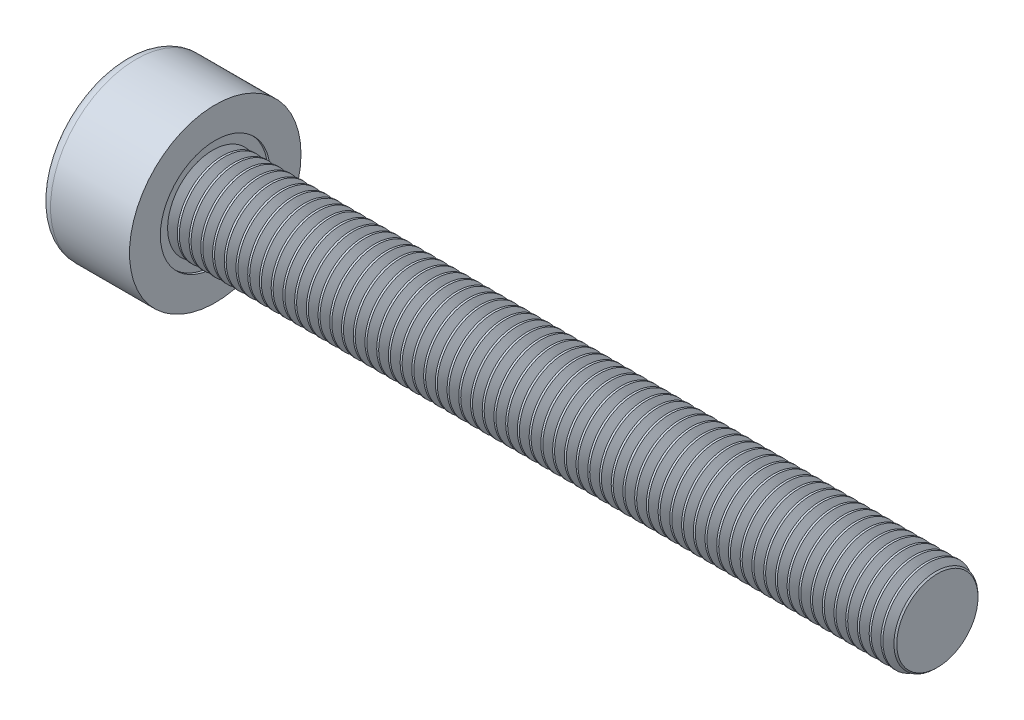
from build123d import *

# Parameters (mm, degrees)
SKETCH1_R           = 1.9
BASEHEAD_DEPTH      = 2
SKETCH2_R           = 1
BASEBODY_DEPTH      = 16
HEXAGONSOCKET_DEPTH = 1
TOPFILLET_R         = 0.25
CHAMFER1_SIZE       = 0.1
LPATTERN10_COUNT    = 62
LPATTERN10_PITCH    = 0.2598


with BuildPart() as part:
    # Sketch1 → BaseHead (new body)
    with BuildSketch(Plane(origin=(0, 0, 0), x_dir=(0, 0, -1), z_dir=(1, 0, 0))):
        Circle(SKETCH1_R)
    extrude(amount=BASEHEAD_DEPTH)

    # Sketch2 → BaseBody (add)
    with BuildSketch(Plane(origin=(2, 0, 0), x_dir=(0, 0, -1), z_dir=(1, 0, 0))):
        Circle(SKETCH2_R)
    extrude(amount=BASEBODY_DEPTH)

    # Sketch3 → HexagonSocket (cut)
    with BuildSketch(Plane(origin=(0, 0, 0), x_dir=(0, 0, -1), z_dir=(1, 0, 0))):
        Polygon((0.866025404, 0), (0.433012702, 0.75), (-0.433012702, 0.75), (-0.866025404, 0), (-0.433012702, -0.75), (0.433012702, -0.75), align=None)
    extrude(amount=HEXAGONSOCKET_DEPTH, mode=Mode.SUBTRACT)

    # Sketch4 → Cut-Revolve1 (revolve, cut)
    with BuildSketch(Plane(origin=(-4.19613823, 0.75, 0), x_dir=(-1, 0, 0), z_dir=(0, 0, 1))):
        Polygon((-5.19613823, 1.5), (-5.629150931, 0.75), (-5.19613823, 0.75), align=None)
    revolve(axis=Axis((0.838992387, 0, 0), (-1, 0, 0)), mode=Mode.SUBTRACT)

    # TopFillet
    topfillet_edges = [part.edges().sort_by_distance(p)[0] for p in [
        (0, 0, 1.9),
    ]]
    fillet(topfillet_edges, radius=TOPFILLET_R)

    # Chamfer1
    chamfer1_edges = [part.edges().sort_by_distance(p)[0] for p in [
        (18, 0, 1),
    ]]
    chamfer(chamfer1_edges, length=CHAMFER1_SIZE)

    # Sketch5 → Cut-Revolve10 (revolve, cut)
    with BuildSketch(Plane.XY):
        Polygon((17.9, 0.8125055), (18.00825, 1), (18.00825, 1.2165), (17.79175, 1.2165), (17.79175, 1), align=None)
    cut_revolve10 = revolve(axis=Axis((0, 0, 0), (1, 0, 0)), mode=Mode.SUBTRACT)

    # LPattern10: Cut-Revolve10 ×62
    with Locations(*[(-i * LPATTERN10_PITCH, 0, 0) for i in range(1, LPATTERN10_COUNT)]):
        add(cut_revolve10, mode=Mode.SUBTRACT)


solid = part.part
